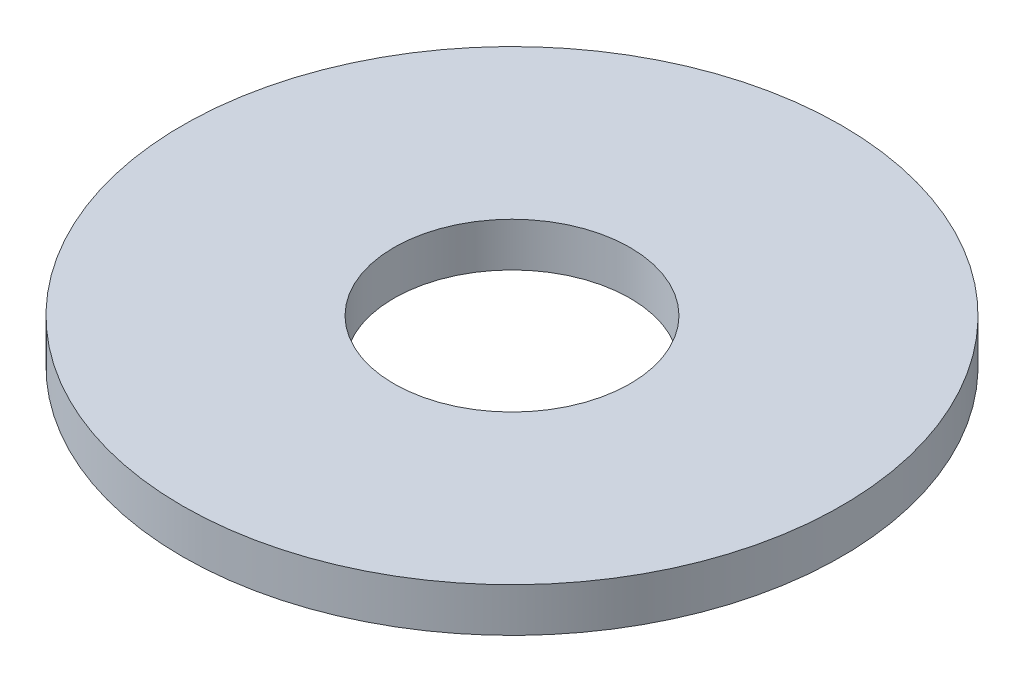
from build123d import *

# Parameters (mm, degrees)
SCHIZZO1_R                   = 6
SCHIZZO1_R_2                 = 2.15
ESTRUSIONE_ESTRUSIONE1_DEPTH = 0.8
SCALE3_SCALE                 = 1.5


with BuildPart() as part:
    # Schizzo1 → Estrusione-Estrusione1 (new body)
    with BuildSketch(Plane(origin=(0, 0, 0), x_dir=(1, 0, 0), z_dir=(0, 1, 0))):
        Circle(SCHIZZO1_R)
        Circle(SCHIZZO1_R_2, mode=Mode.SUBTRACT)
    extrude(amount=ESTRUSIONE_ESTRUSIONE1_DEPTH)


with BuildPart() as part_1:
    # Scale3: scaled about (0, 0.4, 0)
    add(part.part.scale(SCALE3_SCALE).moved(Location((0, -0.2, 0))))


solid = part_1.part
